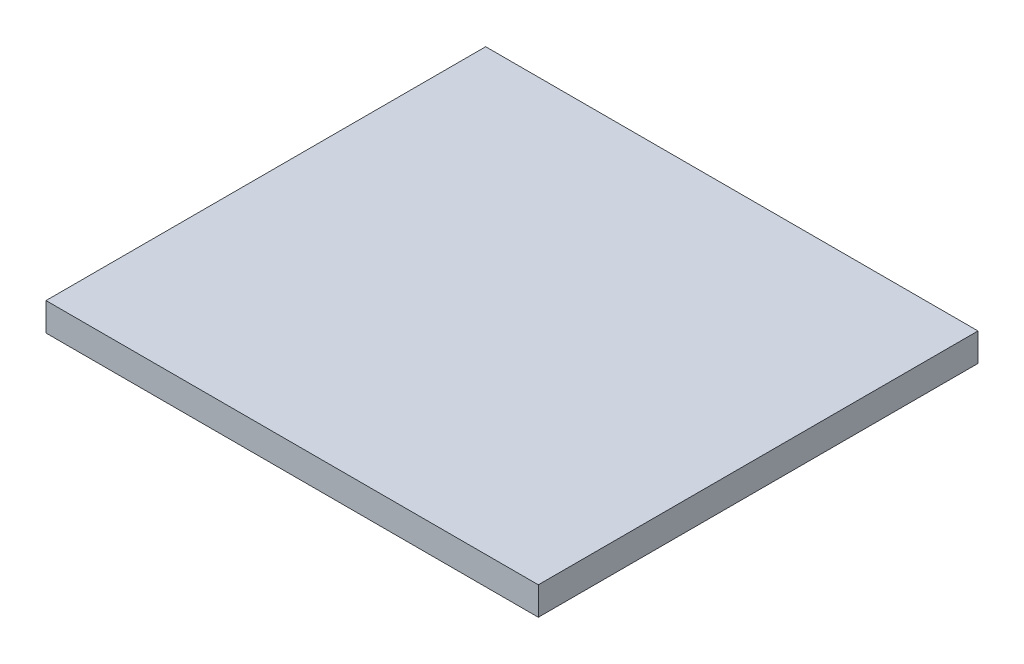
from build123d import *

# Parameters (mm, degrees)
SKETCH1_W           = 666.2
SKETCH1_H           = 594.97
BOSS_EXTRUDE1_DEPTH = 38.1


with BuildPart() as part:
    # Sketch1 → Boss-Extrude1 (new body)
    with BuildSketch(Plane(origin=(0, 0, 0), x_dir=(1, 0, 0), z_dir=(0, 1, 0))):
        Rectangle(SKETCH1_W, SKETCH1_H)
    extrude(amount=BOSS_EXTRUDE1_DEPTH)


solid = part.part
